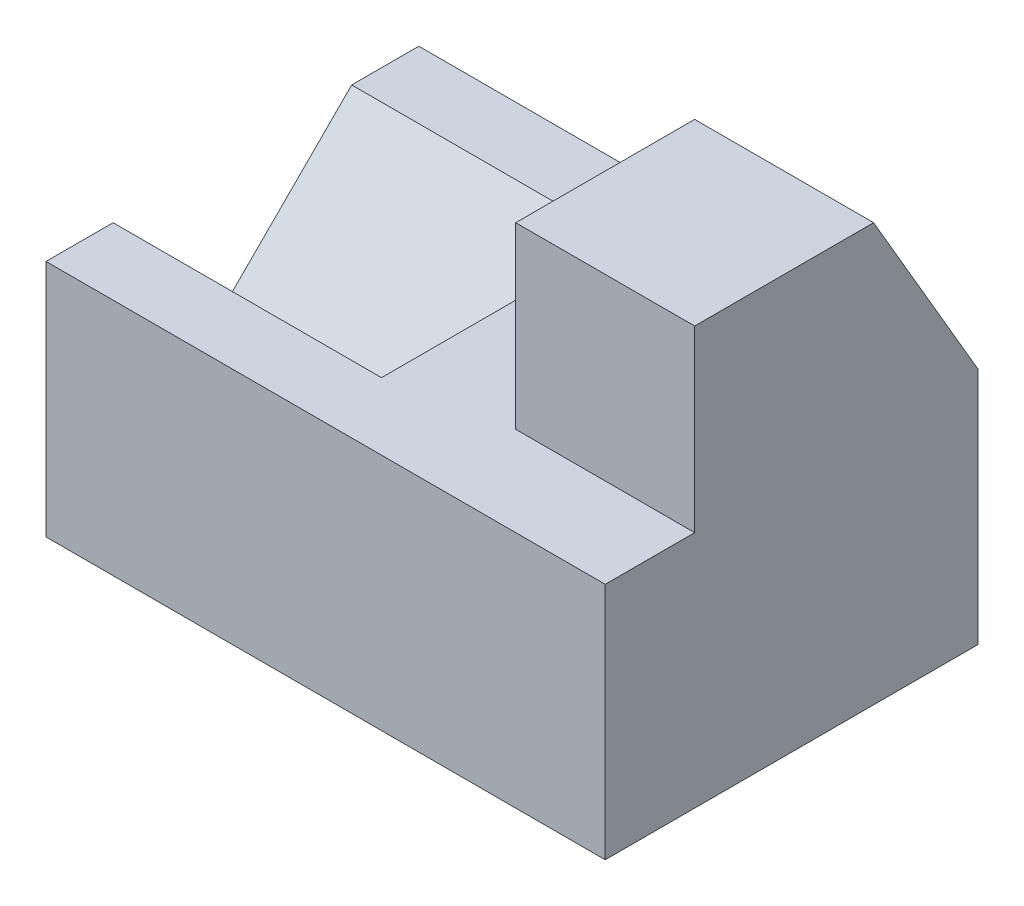
from build123d import *

# Parameters (mm, degrees)
SKETCH2_W           = 75
SKETCH2_H           = 50
BOSS_EXTRUDE1_DEPTH = 32
CUT_EXTRUDE1_DEPTH  = 36
SKETCH5_W           = 24
SKETCH5_H           = 24
BOSS_EXTRUDE3_DEPTH = 24
BOSS_EXTRUDE4_DEPTH = 24


with BuildPart() as part:
    # Sketch2 → Boss-Extrude1 (new body)
    with BuildSketch(Plane(origin=(0, 0, 0), x_dir=(1, 0, 0), z_dir=(0, 1, 0))):
        with Locations((1.812039309, 0.877582126)):
            Rectangle(SKETCH2_W, SKETCH2_H)
    extrude(amount=BOSS_EXTRUDE1_DEPTH)

    # Sketch4 → Cut-Extrude1 (cut)
    with BuildSketch(Plane.ZY.offset(35.687960691)):
        Polygon((-16.877582126, 32), (-0.877582126, 16), (15.122417874, 32), align=None)
    extrude(amount=-CUT_EXTRUDE1_DEPTH, mode=Mode.SUBTRACT)

    # Sketch5 → Boss-Extrude3 (add)
    with BuildSketch(Plane(origin=(0, 32, 0), x_dir=(1, 0, 0), z_dir=(0, 1, 0))):
        with Locations((27.312039309, -0.122417874)):
            Rectangle(SKETCH5_W, SKETCH5_H)
    extrude(amount=BOSS_EXTRUDE3_DEPTH)

    # Sketch6 → Boss-Extrude4 (add)
    with BuildSketch(Plane(origin=(39.312039309, 0, 0), x_dir=(0, 0, -1), z_dir=(1, 0, 0))):
        Polygon((11.877582126, 56), (25.877582126, 32), (11.877582126, 32), align=None)
    extrude(amount=-BOSS_EXTRUDE4_DEPTH)


solid = part.part
